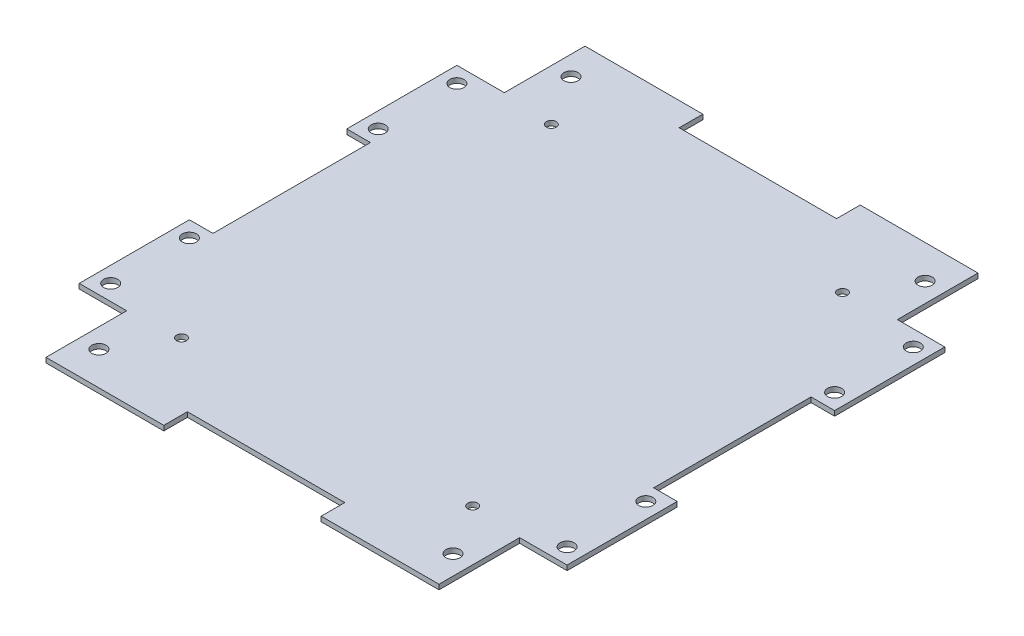
from build123d import *

# Parameters (mm, degrees)
SKETCH1_R           = 2.286
MAIN_BODY_DEPTH     = 1.5875
SKETCH2_R           = 2.286
MOUNT_HOLES_DEPTH   = 2.5875
SKETCH3_R           = 1.5875
OLD_PCB_HOLES_DEPTH = 2.54


with BuildPart() as part:
    # Sketch1 → Main Body (new body)
    with BuildSketch(Plane(origin=(0, 0, 0), x_dir=(1, 0, 0), z_dir=(0, 1, 0))):
        Polygon((-25.4, 86.995), (-63.43142, 86.995), (-63.43142, 60.96), (-78.74, 60.96), (-78.74, 25.4), (-71.12, 25.4), (-71.12, -25.4), (-78.74, -25.4), (-78.74, -60.96), (-63.43142, -60.96), (-63.43142, -86.995), (-25.4, -86.995), (-25.4, -79.375), (25.4, -79.375), (25.4, -86.995), (63.43142, -86.995), (63.43142, -60.96), (78.74, -60.96), (78.74, -25.4), (71.12, -25.4), (71.12, 25.4), (78.74, 25.4), (78.74, 60.96), (63.43142, 60.96), (63.43142, 86.995), (25.4, 86.995), (25.4, 79.375), (-25.4, 79.375), align=None)
        with Locations((-57.15, 76.2)):
            Circle(SKETCH1_R, mode=Mode.SUBTRACT)
        with Locations((57.15, 76.2)):
            Circle(SKETCH1_R, mode=Mode.SUBTRACT)
        with Locations((57.15, -76.2)):
            Circle(SKETCH1_R, mode=Mode.SUBTRACT)
        with Locations((-57.15, -76.2)):
            Circle(SKETCH1_R, mode=Mode.SUBTRACT)
    extrude(amount=MAIN_BODY_DEPTH)

    # Sketch2 → Mount Holes (cut, through all)
    with BuildSketch(Plane(origin=(0, 1.5875, 0), x_dir=(1, 0, 0), z_dir=(0, 1, 0))):
        with Locations((-73.66, -30.48)):
            Circle(SKETCH2_R)
        with Locations((-73.66, -55.88)):
            Circle(SKETCH2_R)
        with Locations((73.66, -55.88)):
            Circle(SKETCH2_R)
        with Locations((73.66, -30.48)):
            Circle(SKETCH2_R)
        with Locations((73.66, 30.48)):
            Circle(SKETCH2_R)
        with Locations((73.66, 55.88)):
            Circle(SKETCH2_R)
        with Locations((-73.66, 55.88)):
            Circle(SKETCH2_R)
        with Locations((-73.66, 30.48)):
            Circle(SKETCH2_R)
    extrude(amount=-MOUNT_HOLES_DEPTH, mode=Mode.SUBTRACT)

    # Sketch3 → Old PCB Holes (cut)
    with BuildSketch(Plane(origin=(0, 1.5875, 0), x_dir=(1, 0, 0), z_dir=(0, 1, 0))):
        with Locations((46.99, -59.69)):
            Circle(SKETCH3_R)
        with Locations((-46.99, -59.69)):
            Circle(SKETCH3_R)
        with Locations((-46.99, 59.69)):
            Circle(SKETCH3_R)
        with Locations((46.99, 59.69)):
            Circle(SKETCH3_R)
    extrude(amount=-OLD_PCB_HOLES_DEPTH, mode=Mode.SUBTRACT)


solid = part.part
